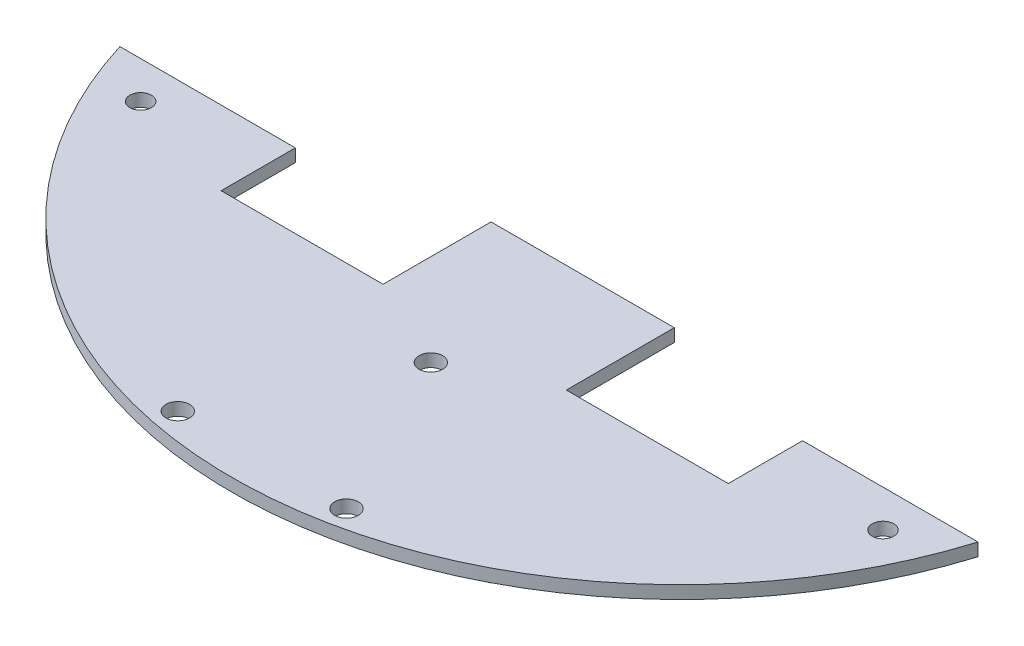
from build123d import *

# Parameters (mm, degrees)
SKETCH1_W           = 36
SKETCH1_H           = 20
BOSS_EXTRUDE1_DEPTH = 1.9
BOSS_EXTRUDE2_DEPTH = 1.9
SKETCH5_W           = 59.232531926
SKETCH5_H           = 32.087665796
CUT_EXTRUDE2_DEPTH  = 10
SKETCH10_R          = 1.75
CUT_EXTRUDE3_DEPTH  = 10
SKETCH11_R          = 1.6
CUT_EXTRUDE4_DEPTH  = 4


with BuildPart() as part:
    # Sketch1 → Boss-Extrude1 (new body)
    with BuildSketch(Plane(origin=(0, 0, 0), x_dir=(1, 0, 0), z_dir=(0, 1, 0))):
        Rectangle(SKETCH1_W, SKETCH1_H)
    extrude(amount=BOSS_EXTRUDE1_DEPTH)

    # Sketch5 → Cut-Extrude2 (cut)
    with BuildSketch(Plane(origin=(0, 1.9, 0), x_dir=(1, 0, 0), z_dir=(0, 1, 0))):
        Rectangle(SKETCH5_W, SKETCH5_H)
    extrude(amount=-CUT_EXTRUDE2_DEPTH, mode=Mode.SUBTRACT)


with BuildPart() as body_2:
    # Sketch3 → Boss-Extrude2 (new body)
    with BuildSketch(Plane.XZ):
        with BuildLine():
            Line((-37.576725301, 45.574302205), (-37.576725301, 56.574302205))
            Line((-37.576725301, 56.574302205), (-13.576725301, 56.574302205))
            Line((-13.576725301, 56.574302205), (-13.576725301, 40.574302205))
            Line((-13.576725301, 40.574302205), (13.576725301, 40.574302205))
            Line((13.576725301, 40.574302205), (13.576725301, 56.574302205))
            Line((13.576725301, 56.574302205), (37.576725301, 56.574302205))
            Line((37.576725301, 56.574302205), (37.576725301, 45.574302205))
            Line((37.576725301, 45.574302205), (63.576725301, 45.574302205))
            ThreePointArc((63.576725301, 45.574302205), (0, 92.574302205), (-63.576725301, 45.574302205))
            Line((-63.576725301, 45.574302205), (-37.576725301, 45.574302205))
        make_face()
    extrude(amount=-BOSS_EXTRUDE2_DEPTH)

    # Sketch10 → Cut-Extrude3 (cut)
    with BuildSketch(Plane(origin=(0, 1.9, 0), x_dir=(1, 0, 0), z_dir=(0, 1, 0))):
        with Locations((-12.5, -88.074302205)):
            Circle(SKETCH10_R)
        with Locations((12.5, -88.074302205)):
            Circle(SKETCH10_R)
        with Locations((0, -63.074302205)):
            Circle(SKETCH10_R)
    extrude(amount=-CUT_EXTRUDE3_DEPTH, mode=Mode.SUBTRACT)

    # Sketch11 → Cut-Extrude4 (cut)
    with BuildSketch(Plane.XZ):
        with Locations((-55, 51.074302205)):
            Circle(SKETCH11_R)
        with Locations((55, 51.074302205)):
            Circle(SKETCH11_R)
    extrude(amount=-CUT_EXTRUDE4_DEPTH, mode=Mode.SUBTRACT)


solid = body_2.part
